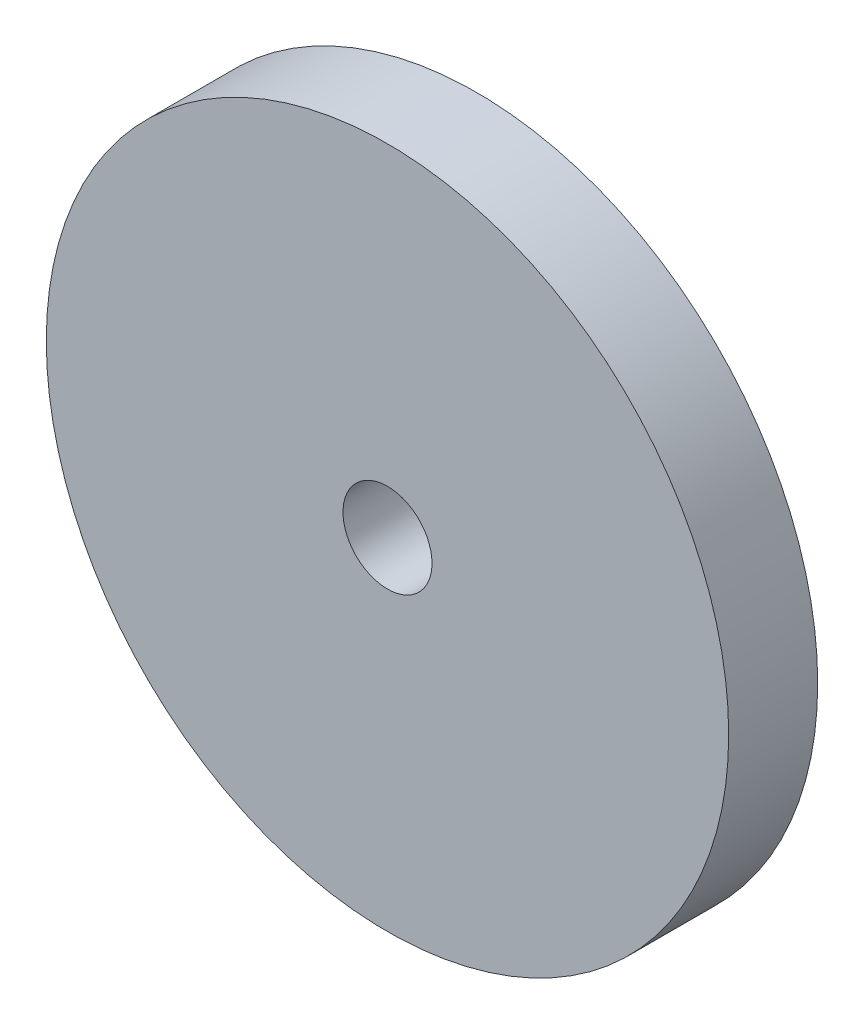
from build123d import *

# Parameters (mm, degrees)
CROQUIS1_R              = 11.5
CROQUIS1_R_2            = 1.5
SALIENTE_EXTRUIR1_DEPTH = 3


with BuildPart() as part:
    # Croquis1 → Saliente-Extruir1 (new body)
    with BuildSketch(Plane.XY):
        Circle(CROQUIS1_R)
        Circle(CROQUIS1_R_2, mode=Mode.SUBTRACT)
    extrude(amount=SALIENTE_EXTRUIR1_DEPTH)


solid = part.part
